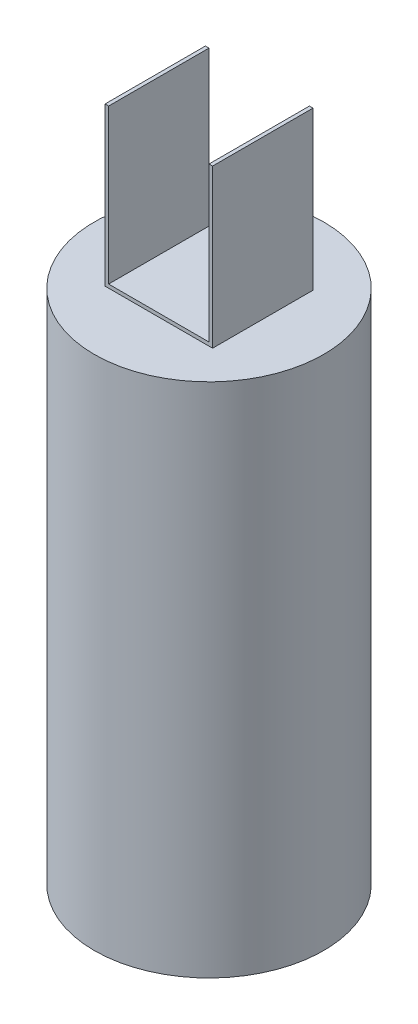
from build123d import *

# Parameters (mm, degrees)
SKETCH1_R           = 101.6
BOSS_EXTRUDE1_DEPTH = 457.2
SKETCH2_W           = 3.175
SKETCH2_H           = 88.9
BOSS_EXTRUDE3_DEPTH = 139.7
SKETCH2_3_W         = 88.9
SKETCH2_3_H         = 88.9
BOSS_EXTRUDE4_DEPTH = 3.175


with BuildPart() as part:
    # Sketch1 → Boss-Extrude1 (new body)
    with BuildSketch(Plane(origin=(0, 0, 0), x_dir=(1, 0, 0), z_dir=(0, 1, 0))):
        Circle(SKETCH1_R)
    extrude(amount=BOSS_EXTRUDE1_DEPTH)

    # Sketch2 → Boss-Extrude3 (add)
    with BuildSketch(Plane(origin=(0, 457.2, 0), x_dir=(1, 0, 0), z_dir=(0, 1, 0))):
        with Locations((-46.0375, 0)):
            Rectangle(SKETCH2_W, SKETCH2_H)
        with Locations((46.0375, 0)):
            Rectangle(SKETCH2_W, SKETCH2_H)
    extrude(amount=BOSS_EXTRUDE3_DEPTH)

    # Sketch2_3 → Boss-Extrude4 (add)
    with BuildSketch(Plane(origin=(0, 457.2, 0), x_dir=(1, 0, 0), z_dir=(0, 1, 0))):
        Rectangle(SKETCH2_3_W, SKETCH2_3_H)
    extrude(amount=BOSS_EXTRUDE4_DEPTH)


solid = part.part
